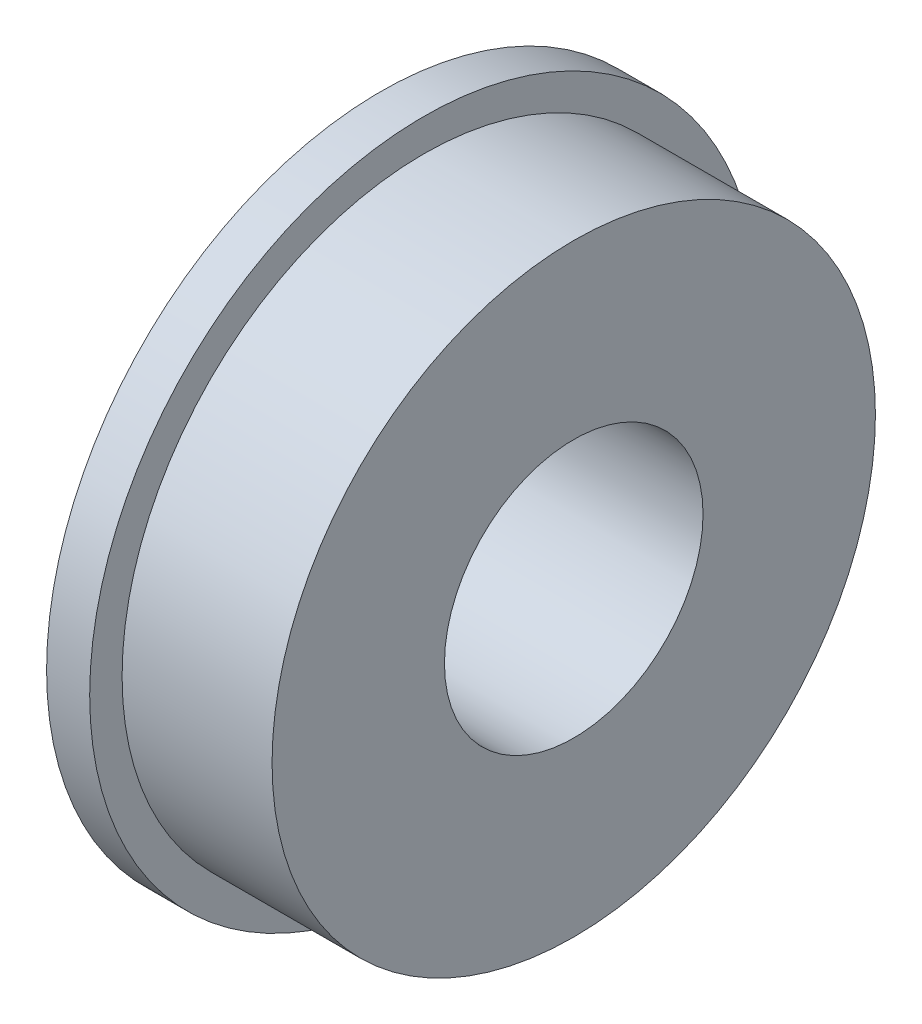
from build123d import *


with BuildPart() as part:
    # Sketch1 → Revolve1 (revolve)
    with BuildSketch(Plane(origin=(0, 0, 0), x_dir=(-1, 0, 0), z_dir=(0, 0, -1))):
        Polygon((-0.381, 6.35), (-0.381, 9.906), (0, 9.906), (0, 12.3063), (-1.5875, 12.3063), (-1.5875, 11.1125), (-7.112, 11.1125), (-7.112, 4.7625), (0, 4.7625), (0, 6.35), align=None)
    revolve(axis=Axis((7.112, 0, 0), (-1, 0, 0)))


solid = part.part
